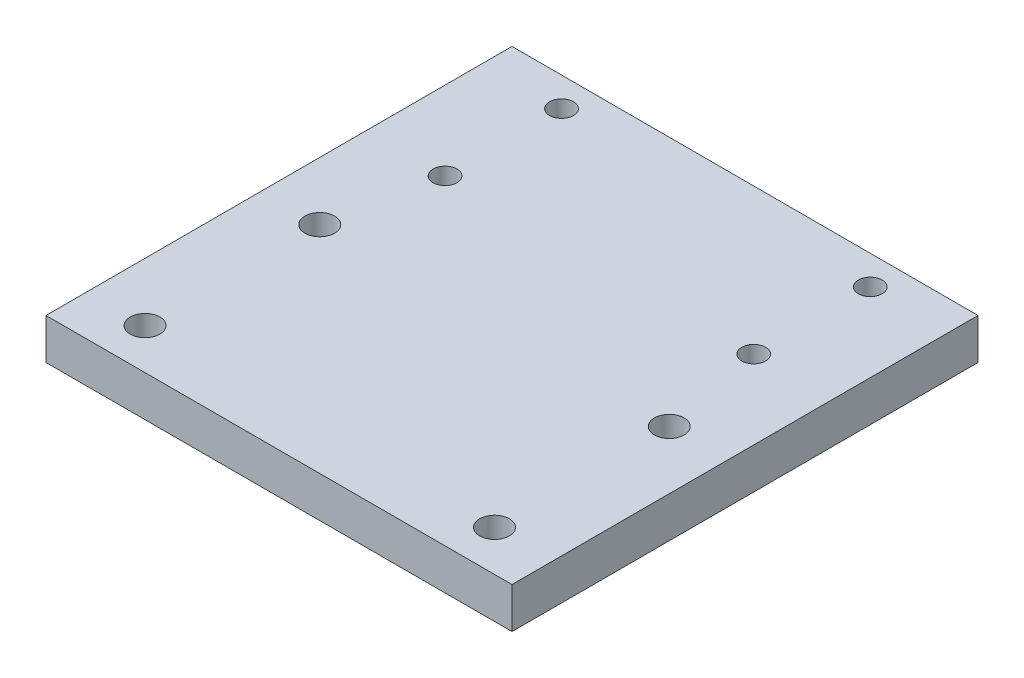
from build123d import *

# Parameters (mm, degrees)
SKETCH1_W                               = 80
SKETCH1_H                               = 80
SKETCH1_R                               = 2.55
SKETCH1_R_2                             = 2.05
BOSS_EXTRUDE1_DEPTH                     = 7
CBORE_FOR_5_64_EJECTOR_PIN1_D           = 1.984375
CBORE_FOR_5_64_EJECTOR_PIN1_CBORE_D     = 5.953125
CBORE_FOR_5_64_EJECTOR_PIN1_CBORE_DEPTH = 2.175


with BuildPart() as part:
    # Sketch1 → Boss-Extrude1 (new body)
    with BuildSketch(Plane(origin=(0, 0, 0), x_dir=(1, 0, 0), z_dir=(0, 1, 0))):
        with Locations((0, 18)):
            Rectangle(SKETCH1_W, SKETCH1_H)
        with Locations((-30, 15)):
            Circle(SKETCH1_R, mode=Mode.SUBTRACT)
        with Locations((30, 15)):
            Circle(SKETCH1_R, mode=Mode.SUBTRACT)
        with Locations((30, -15)):
            Circle(SKETCH1_R, mode=Mode.SUBTRACT)
        with Locations((-30, -15)):
            Circle(SKETCH1_R, mode=Mode.SUBTRACT)
        with Locations((-26.5, 53)):
            Circle(SKETCH1_R_2, mode=Mode.SUBTRACT)
        with Locations((26.5, 53)):
            Circle(SKETCH1_R_2, mode=Mode.SUBTRACT)
        with Locations((26.5, 33)):
            Circle(SKETCH1_R_2, mode=Mode.SUBTRACT)
        with Locations((-26.5, 33)):
            Circle(SKETCH1_R_2, mode=Mode.SUBTRACT)
    extrude(amount=BOSS_EXTRUDE1_DEPTH)

    # CBORE for 5/64 Ejector Pin1 (through all)
    with Locations(Plane(origin=(0, 0, 0), x_dir=(-1, 0, 0), z_dir=(0, -1, 0))):
        with Locations((26.5, 33), (-26.5, 33), (26.5, 53), (-26.5, 53)):
            CounterBoreHole(CBORE_FOR_5_64_EJECTOR_PIN1_D / 2, CBORE_FOR_5_64_EJECTOR_PIN1_CBORE_D / 2, CBORE_FOR_5_64_EJECTOR_PIN1_CBORE_DEPTH)


solid = part.part
